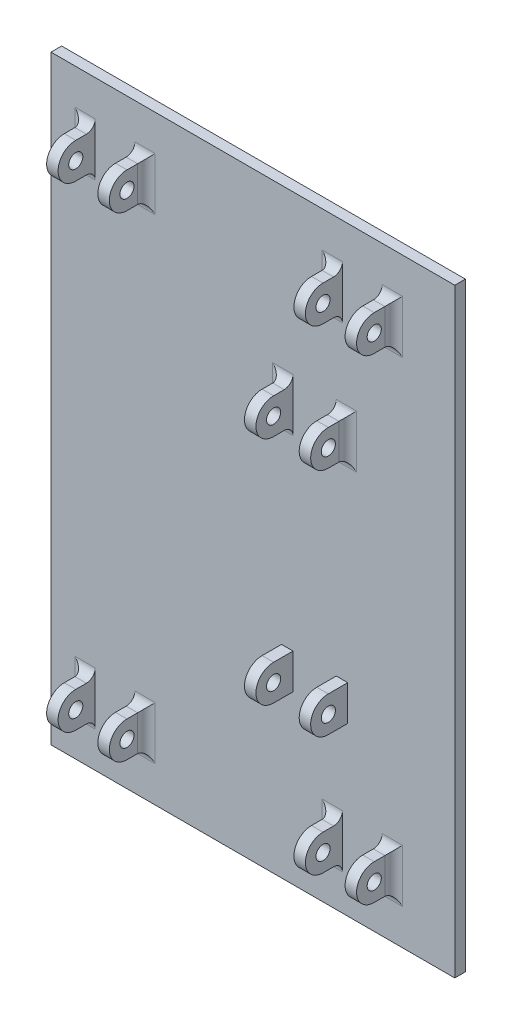
from build123d import *

# Parameters (mm, degrees)
SKETCH1_W               = 228.6
SKETCH1_H               = 339.725
BOSS_EXTRUDE1_DEPTH     = 6
SKETCH2_W               = 6.5
SKETCH2_H               = 20
BOSS_EXTRUDE2_DEPTH     = 24
CUT_EXTRUDE1_DEPTH      = 401.568453108
CUT_EXTRUDE1_DEPTH_BACK = 401.568453108
SKETCH3_R               = 4
FILLET2_R               = 5


with BuildPart() as part:
    # Sketch1 → Boss-Extrude1 (new body)
    with BuildSketch(Plane.XY):
        with Locations((114.3, -169.8625)):
            Rectangle(SKETCH1_W, SKETCH1_H)
    extrude(amount=BOSS_EXTRUDE1_DEPTH)

    # Sketch2 → Boss-Extrude2 (add)
    with BuildSketch(Plane.XY.offset(6)):
        with Locations((21.75, -35.2425)):
            Rectangle(SKETCH2_W, SKETCH2_H)
        with Locations((50.75, -35.2425)):
            Rectangle(SKETCH2_W, SKETCH2_H)
        with Locations((161.75, -35.2425)):
            Rectangle(SKETCH2_W, SKETCH2_H)
        with Locations((190.75, -35.2425)):
            Rectangle(SKETCH2_W, SKETCH2_H)
        with Locations((133.75086248, -104.5325)):
            Rectangle(SKETCH2_W, SKETCH2_H)
        with Locations((164.75086248, -104.5325)):
            Rectangle(SKETCH2_W, SKETCH2_H)
        with Locations((164.75086248, -235.1925)):
            Rectangle(SKETCH2_W, SKETCH2_H)
        with Locations((21.75, -304.4825)):
            Rectangle(SKETCH2_W, SKETCH2_H)
        with Locations((50.75, -304.4825)):
            Rectangle(SKETCH2_W, SKETCH2_H)
        with Locations((190.75, -304.4825)):
            Rectangle(SKETCH2_W, SKETCH2_H)
        with Locations((161.75, -304.4825)):
            Rectangle(SKETCH2_W, SKETCH2_H)
        with Locations((133.75086248, -235.1925)):
            Rectangle(SKETCH2_W, SKETCH2_H)
    extrude(amount=BOSS_EXTRUDE2_DEPTH)

    # Sketch3 → Cut-Extrude1 (cut, two sides: drawn at the far end of the back side and taken through both)
    with BuildSketch(Plane.ZY.offset(-18.5).offset(-CUT_EXTRUDE1_DEPTH_BACK)):
        with Locations((17, -35.2425)):
            Circle(SKETCH3_R)
        with Locations((17, -235.1925)):
            Circle(SKETCH3_R)
        with Locations((17, -304.4825)):
            Circle(SKETCH3_R)
        with Locations((17, -104.5325)):
            Circle(SKETCH3_R)
        with BuildLine():
            Line((17, -25.2425), (17, -12.982943413))
            Line((17, -12.982943413), (50.949532367, -12.982943413))
            Line((50.949532367, -12.982943413), (50.949532367, -57.481006387))
            Line((50.949532367, -57.481006387), (17, -57.481006387))
            Line((17, -57.481006387), (17, -45.2425))
            ThreePointArc((17, -45.2425), (27, -35.2425), (17, -25.2425))
        make_face()
        with BuildLine():
            Line((51.442304634, -132.399123951), (17, -132.399123951))
            Line((17, -132.399123951), (17, -114.5325))
            ThreePointArc((17, -114.5325), (27, -104.5325), (17, -94.5325))
            Line((17, -94.5325), (17, -71.59149594))
            Line((17, -71.59149594), (51.442304634, -71.59149594))
            Line((51.442304634, -71.59149594), (51.442304634, -132.399123951))
        make_face()
        with BuildLine():
            Line((51.599532243, -270.375386727), (17, -270.375386727))
            Line((17, -270.375386727), (17, -245.1925))
            ThreePointArc((17, -245.1925), (27, -235.1925), (17, -225.1925))
            Line((17, -225.1925), (17, -207.306351849))
            Line((17, -207.306351849), (51.599532243, -207.306351849))
            Line((51.599532243, -207.306351849), (51.599532243, -270.375386727))
        make_face()
        with BuildLine():
            Line((51.621034016, -326.721115515), (17, -326.721115515))
            Line((17, -326.721115515), (17, -314.4825))
            ThreePointArc((17, -314.4825), (27, -304.4825), (17, -294.4825))
            Line((17, -294.4825), (17, -282.222834285))
            Line((17, -282.222834285), (51.621034016, -282.222834285))
            Line((51.621034016, -282.222834285), (51.621034016, -326.721115515))
        make_face()
    extrude(amount=CUT_EXTRUDE1_DEPTH + CUT_EXTRUDE1_DEPTH_BACK, mode=Mode.SUBTRACT)

    # Fillet2
    fillet2_edges = [part.edges().sort_by_distance(p)[0] for p in [
        (158.5, -304.4825, 6),
        (18.5, -304.4825, 6),
        (21.75, -45.2425, 6),
        (18.5, -35.2425, 6),
        (21.75, -25.2425, 6),
        (50.75, -25.2425, 6),
        (50.75, -45.2425, 6),
        (54, -35.2425, 6),
        (161.75, -25.2425, 6),
        (190.75, -25.2425, 6),
        (194, -35.2425, 6),
        (190.75, -45.2425, 6),
        (161.75, -45.2425, 6),
        (158.5, -35.2425, 6),
        (168.00086248, -104.5325, 6),
        (164.75086248, -114.5325, 6),
        (133.75086248, -114.5325, 6),
        (130.50086248, -104.5325, 6),
        (164.75086248, -94.5325, 6),
        (133.75086248, -94.5325, 6),
        (21.75, -294.4825, 6),
        (50.75, -294.4825, 6),
        (54, -304.4825, 6),
        (194, -304.4825, 6),
        (161.75, -294.4825, 6),
        (190.75, -294.4825, 6),
        (190.75, -314.4825, 6),
        (161.75, -314.4825, 6),
        (50.75, -314.4825, 6),
        (21.75, -314.4825, 6),
    ]]
    fillet(fillet2_edges, radius=FILLET2_R)


solid = part.part
